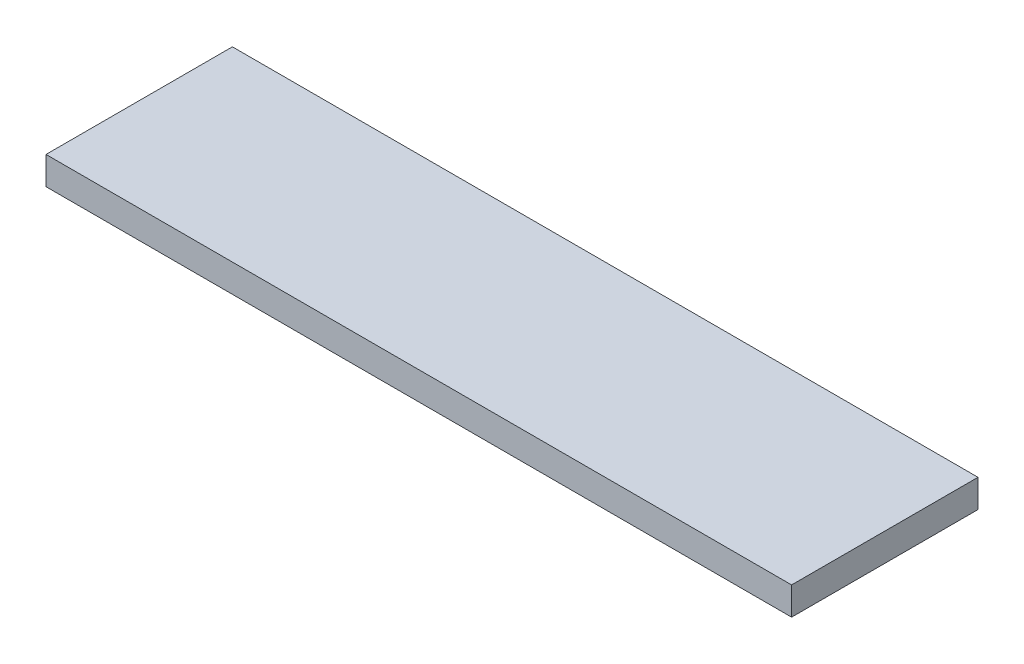
from build123d import *

# Parameters (mm, degrees)
ESQUISSE1_W        = 400
ESQUISSE1_H        = 100
BOSS_EXTRU_1_DEPTH = 15


with BuildPart() as part:
    # Esquisse1 → Boss.-Extru.1 (new body)
    with BuildSketch(Plane(origin=(0, 0, 0), x_dir=(1, 0, 0), z_dir=(0, 1, 0))):
        with Locations((200, 50)):
            Rectangle(ESQUISSE1_W, ESQUISSE1_H)
    extrude(amount=BOSS_EXTRU_1_DEPTH)


solid = part.part
